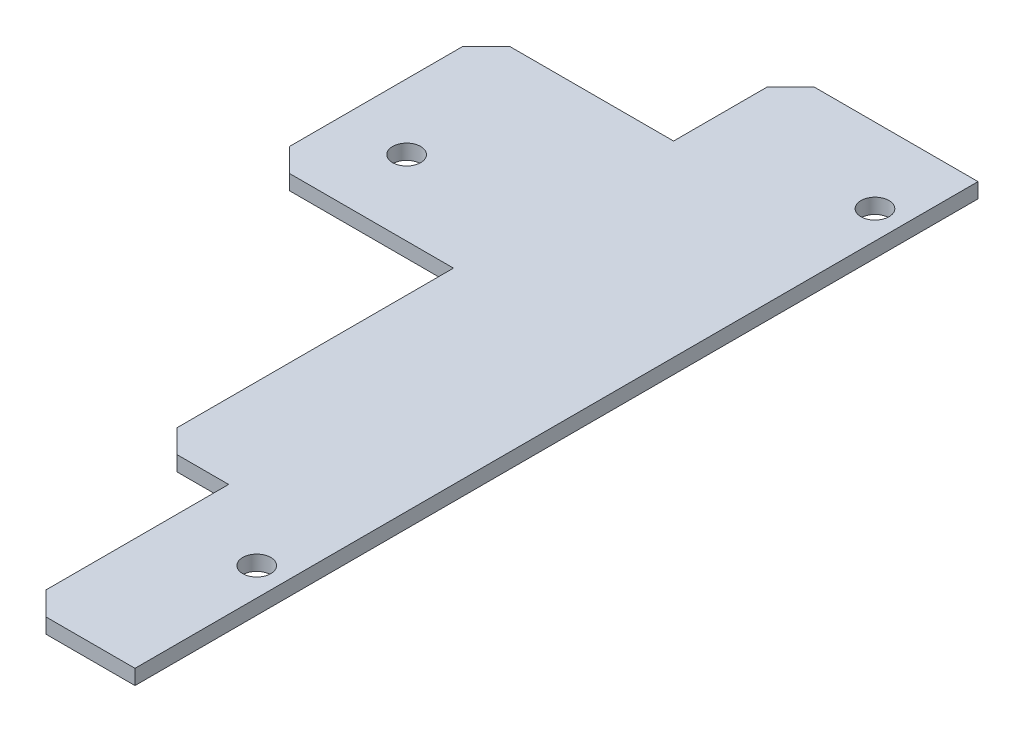
from build123d import *

# Parameters (mm, degrees)
EXTRUDE1_DEPTH     = 1.6
SKETCH2_R          = 1.5
SKETCH2_W          = 20
SKETCH2_H          = 12.5
CUT_EXTRUDE1_DEPTH = 1.6
CHAMFER1_SIZE      = 2.5


with BuildPart() as part:
    # Sketch1 → Extrude1 (new body)
    with BuildSketch(Plane(origin=(0, 0, 0), x_dir=(1, 0, 0), z_dir=(0, 1, 0))):
        Polygon((0, -32), (8, -32), (8, -54), (20, -54), (20, 36), (-20, 36), (-20, 0), (0, 0), align=None)
    extrude(amount=EXTRUDE1_DEPTH)

    # Sketch2 → Cut-Extrude1 (cut)
    with BuildSketch(Plane(origin=(0, 1.6, 0), x_dir=(1, 0, 0), z_dir=(0, 1, 0))):
        with Locations(Location((17, 28, 0), (0, 0, 270))):  # turned: the seam where the file's is
            Circle(SKETCH2_R)
        with Locations(Location((-13, 8, 0), (0, 0, 270))):  # turned: the seam where the file's is
            Circle(SKETCH2_R)
        with Locations(Location((17, -38, 0), (0, 0, 270))):  # turned: the seam where the file's is
            Circle(SKETCH2_R)
        with Locations((-10, 29.75)):
            Rectangle(SKETCH2_W, SKETCH2_H)
    extrude(amount=-CUT_EXTRUDE1_DEPTH, mode=Mode.SUBTRACT)

    # Chamfer1
    chamfer1_edges = [part.edges().sort_by_distance(p)[0] for p in [
        (8, 0.8, 54),
        (0, 0.8, 32),
        (-20, 0.8, 0),
        (-20, 0.8, -23.5),
        (0, 0.8, -36),
    ]]
    chamfer(chamfer1_edges, length=CHAMFER1_SIZE)


solid = part.part
